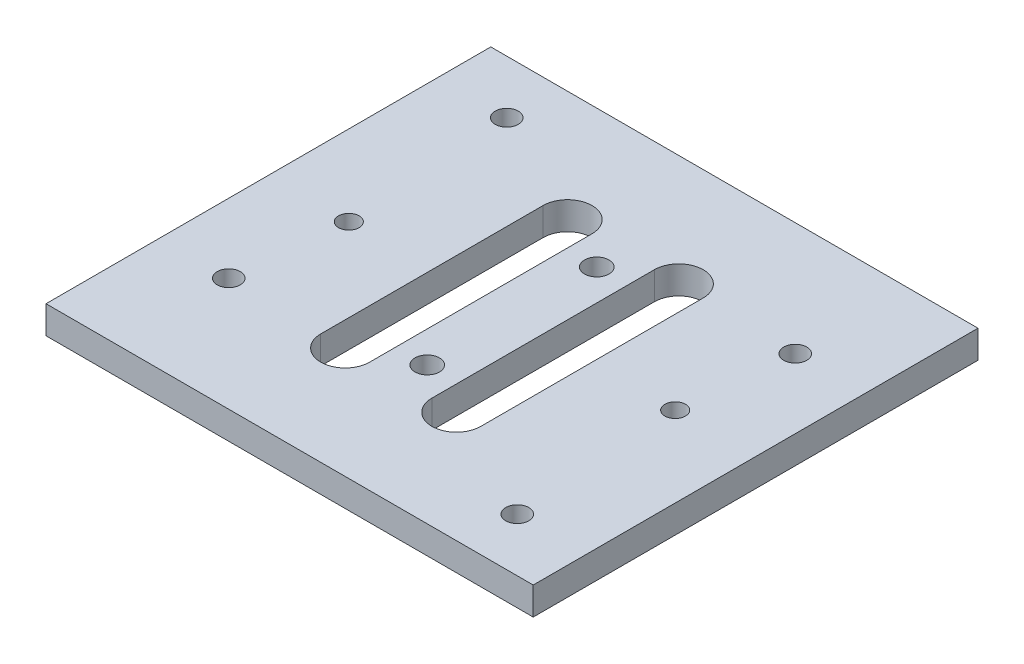
from build123d import *

# Parameters (mm, degrees)
SKETCH1_W           = 87.63
SKETCH1_H           = 80
BOSS_EXTRUDE1_DEPTH = 5
SKETCH2_R           = 2.075
SKETCH2_R_2         = 1.85
CUT_EXTRUDE1_DEPTH  = 6
CUT_EXTRUDE2_REACH  = 7
SKETCH3_R           = 2.2
CUT_EXTRUDE3_REACH  = 7


with BuildPart() as part:
    # Sketch1 → Boss-Extrude1 (new body)
    with BuildSketch(Plane(origin=(0, 0, 0), x_dir=(1, 0, 0), z_dir=(0, 1, 0))):
        with Locations((43.815, 40)):
            Rectangle(SKETCH1_W, SKETCH1_H)
    extrude(amount=BOSS_EXTRUDE1_DEPTH)

    # Sketch2 → Cut-Extrude1 (cut, through all)
    with BuildSketch(Plane(origin=(0, 5, 0), x_dir=(1, 0, 0), z_dir=(0, 1, 0))):
        with Locations(Location((12.465, 70.4, 0), (0, 0, 270))):  # turned: the seam where the file's is
            Circle(SKETCH2_R)
        with Locations(Location((12.465, 20.4, 0), (0, 0, 270))):  # turned: the seam where the file's is
            Circle(SKETCH2_R)
        with Locations(Location((14.465, 40, 0), (0, 0, 270))):  # turned: the seam where the file's is
            Circle(SKETCH2_R_2)
        with Locations(Location((73.165, 40, 0), (0, 0, 270))):  # turned: the seam where the file's is
            Circle(SKETCH2_R_2)
        with Locations(Location((75.165, 9.6, 0), (0, 0, 270))):  # turned: the seam where the file's is
            Circle(SKETCH2_R)
        with Locations(Location((75.165, 59.6, 0), (0, 0, 270))):  # turned: the seam where the file's is
            Circle(SKETCH2_R)
    extrude(amount=-CUT_EXTRUDE1_DEPTH, mode=Mode.SUBTRACT)

    # Sketch3 → Cut-Extrude2 (cut, up to next)
    with BuildSketch(Plane(origin=(0, 5, 0), x_dir=(1, 0, 0), z_dir=(0, 1, 0)), mode=Mode.PRIVATE) as cut_extrude2_sk1:
        with Locations(Location((43.81, 55.25, 0), (0, 0, 270))):  # turned: the seam where the file's is
            Circle(SKETCH3_R)
    cut_extrude2_tool1 = extrude(cut_extrude2_sk1.sketch, amount=-CUT_EXTRUDE2_REACH, mode=Mode.PRIVATE) & part.part
    add(cut_extrude2_tool1.solids().sort_by_distance((43.81, 5, -55.25))[0], mode=Mode.SUBTRACT)
    # Sketch3 → Cut-Extrude2 (cut, up to next)
    with BuildSketch(Plane(origin=(0, 5, 0), x_dir=(1, 0, 0), z_dir=(0, 1, 0)), mode=Mode.PRIVATE) as cut_extrude2_sk2:
        with Locations(Location((43.82, 24.75, 0), (0, 0, 270))):  # turned: the seam where the file's is
            Circle(SKETCH3_R)
    cut_extrude2_tool2 = extrude(cut_extrude2_sk2.sketch, amount=-CUT_EXTRUDE2_REACH, mode=Mode.PRIVATE) & part.part
    add(cut_extrude2_tool2.solids().sort_by_distance((43.82, 5, -24.75))[0], mode=Mode.SUBTRACT)

    # Sketch4 → Cut-Extrude3 (cut, up to next)
    with BuildSketch(Plane(origin=(0, 5, 0), x_dir=(1, 0, 0), z_dir=(0, 1, 0)), mode=Mode.PRIVATE) as cut_extrude3_sk1:
        with BuildLine():
            Line((38.21, 60), (38.21, 20))
            ThreePointArc((38.21, 20), (33.81, 15.6), (29.41, 20))
            Line((29.41, 20), (29.41, 60))
            ThreePointArc((29.41, 60), (33.81, 64.4), (38.21, 60))
        make_face()
    cut_extrude3_tool1 = extrude(cut_extrude3_sk1.sketch, amount=-CUT_EXTRUDE3_REACH, mode=Mode.PRIVATE) & part.part
    add(cut_extrude3_tool1.solids().sort_by_distance((33.81, 5, -40))[0], mode=Mode.SUBTRACT)
    # Sketch4 → Cut-Extrude3 (cut, up to next)
    with BuildSketch(Plane(origin=(0, 5, 0), x_dir=(1, 0, 0), z_dir=(0, 1, 0)), mode=Mode.PRIVATE) as cut_extrude3_sk2:
        with BuildLine():
            Line((58.21, 60), (58.21, 20))
            ThreePointArc((58.21, 20), (53.81, 15.6), (49.41, 20))
            Line((49.41, 20), (49.41, 60))
            ThreePointArc((49.41, 60), (53.81, 64.4), (58.21, 60))
        make_face()
    cut_extrude3_tool2 = extrude(cut_extrude3_sk2.sketch, amount=-CUT_EXTRUDE3_REACH, mode=Mode.PRIVATE) & part.part
    add(cut_extrude3_tool2.solids().sort_by_distance((53.81, 5, -40))[0], mode=Mode.SUBTRACT)


solid = part.part
